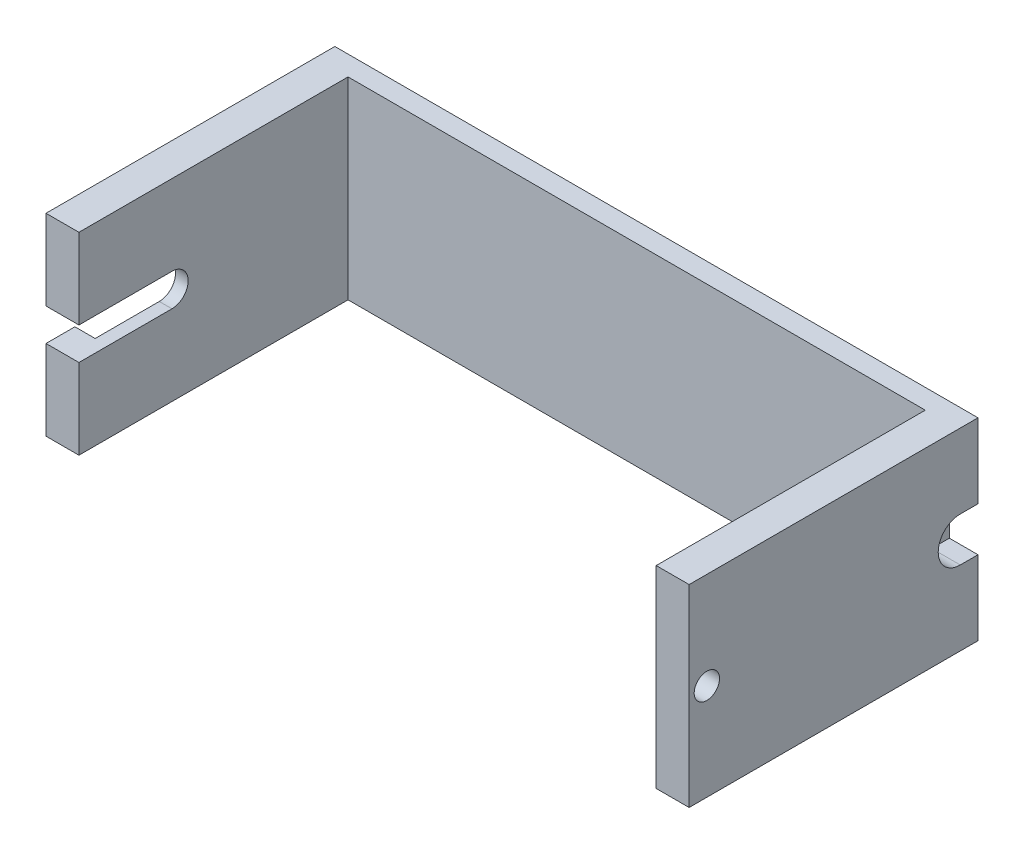
from build123d import *

# Parameters (mm, degrees)
ESBO_O1_W                = 126.9
ESBO_O1_H                = 38.1
RESSALTO_EXTRUS_O2_DEPTH = 3.9
ESBO_O3_W                = 6.5
ESBO_O3_H                = 38.1
RESSALTO_EXTRUS_O3_DEPTH = 53.1
ESBO_O4_W                = 25.3
ESBO_O4_H                = 25.3
ESBO_O4_R                = 3.2
CORTE_EXTRUS_O1_DEPTH    = 4
CORTE_EXTRUS_O2_DEPTH    = 50
CORTE_EXTRUS_O3_DEPTH    = 5.65
ESBO_O9_R                = 2.5
CORTE_EXTRUS_O4_DEPTH    = 10


with BuildPart() as part:
    # Esboço1 → Ressalto-extrusão2 (new body)
    with BuildSketch(Plane.XY):
        with Locations((-63.45, 19.05)):
            Rectangle(ESBO_O1_W, ESBO_O1_H)
    extrude(amount=RESSALTO_EXTRUS_O2_DEPTH)

    # Esboço3 → Ressalto-extrusão3 (add)
    with BuildSketch(Plane.XY.offset(3.9)):
        with Locations((-123.65, 19.05)):
            Rectangle(ESBO_O3_W, ESBO_O3_H)
        with Locations((-3.25, 19.05)):
            Rectangle(ESBO_O3_W, ESBO_O3_H)
    extrude(amount=RESSALTO_EXTRUS_O3_DEPTH)

    # Esboço4 → Corte-extrusão1 (cut)
    with BuildSketch(Plane.ZY.offset(126.9)):
        with Locations((38.65, 19.05)):
            Rectangle(ESBO_O4_W, ESBO_O4_H)
        with Locations((38.65, 19.05)):
            Circle(ESBO_O4_R, mode=Mode.SUBTRACT)
    extrude(amount=-CORTE_EXTRUS_O1_DEPTH, mode=Mode.SUBTRACT)

    # Esboço6 → Corte-extrusão2 (cut)
    with BuildSketch(Plane.ZY.offset(126.9)):
        with BuildLine():
            Line((38.65, 22.25), (57, 22.25))
            Line((57, 22.25), (57, 15.85))
            Line((57, 15.85), (38.65, 15.85))
            ThreePointArc((38.65, 15.85), (35.45, 19.05), (38.65, 22.25))
        make_face()
    extrude(amount=-CORTE_EXTRUS_O2_DEPTH, mode=Mode.SUBTRACT)

    # Esboço7 → Corte-extrusão3 (cut)
    with BuildSketch(Plane(origin=(0, 0, 0), x_dir=(0, 0, -1), z_dir=(1, 0, 0))):
        with BuildLine():
            Line((-3.5, 14.7), (0, 14.7))
            Line((0, 14.7), (0, 23.4))
            Line((0, 23.4), (-3.5, 23.4))
            ThreePointArc((-3.5, 23.4), (-7.85, 19.05), (-3.5, 14.7))
        make_face()
    extrude(amount=-CORTE_EXTRUS_O3_DEPTH, mode=Mode.SUBTRACT)

    # Esboço9 → Corte-extrusão4 (cut)
    with BuildSketch(Plane(origin=(0, 0, 0), x_dir=(0, 0, -1), z_dir=(1, 0, 0))):
        with Locations((-53.5, 19.05)):
            Circle(ESBO_O9_R)
    extrude(amount=-CORTE_EXTRUS_O4_DEPTH, mode=Mode.SUBTRACT)


solid = part.part
